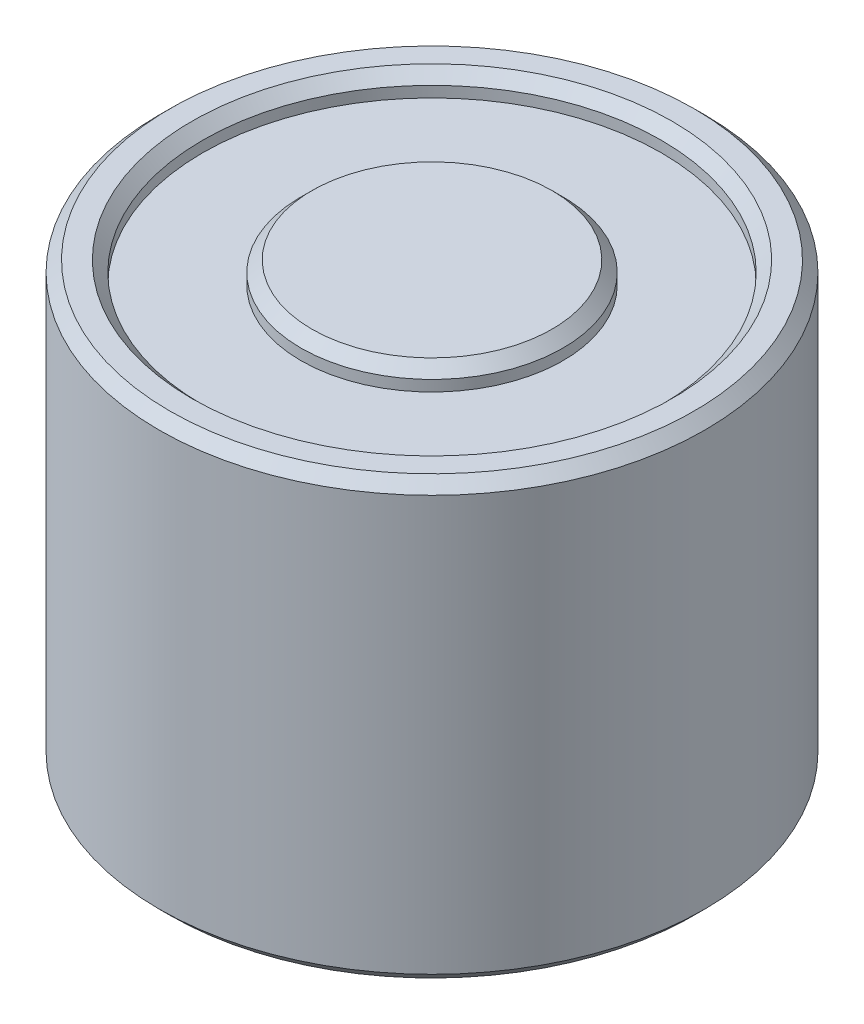
from build123d import *

# Parameters (mm, degrees)
SKETCH_1_R          = 12.5
EXTRUDE_1_DEPTH     = 20
SKETCH_2_R          = 10.5
SKETCH_2_R_2        = 6
CUT_EXTRUDE_1_DEPTH = 1
CHAMFER_1_SIZE      = 0.5
SKETCH_3_R          = 2
CUT_EXTRUDE_2_DEPTH = 12
CHAMFER_2_SIZE      = 1


with BuildPart() as part:
    # Эскиз1 → Бобышка-Вытянуть1 (new body)
    with BuildSketch(Plane(origin=(0, 0, 0), x_dir=(1, 0, 0), z_dir=(0, 1, 0))):
        Circle(SKETCH_1_R)
    extrude(amount=EXTRUDE_1_DEPTH)

    # Эскиз2 → Вырез-Вытянуть1 (cut)
    with BuildSketch(Plane(origin=(0, 20, 0), x_dir=(1, 0, 0), z_dir=(0, 1, 0))):
        Circle(SKETCH_2_R)
        Circle(SKETCH_2_R_2, mode=Mode.SUBTRACT)
    extrude(amount=-CUT_EXTRUDE_1_DEPTH, mode=Mode.SUBTRACT)

    # Фаска1
    chamfer_1_edges = [part.edges().sort_by_distance(p)[0] for p in [
        (-12.5, 0, 0),
        (-12.5, 20, 0),
        (-10.5, 20, 0),
        (-6, 20, 0),
    ]]
    chamfer(chamfer_1_edges, length=CHAMFER_1_SIZE)

    # Эскиз3 → Вырез-Вытянуть2 (cut)
    with BuildSketch(Plane.XZ):
        Circle(SKETCH_3_R)
    extrude(amount=-CUT_EXTRUDE_2_DEPTH, mode=Mode.SUBTRACT)

    # Фаска2
    chamfer_2_edges = [part.edges().sort_by_distance(p)[0] for p in [
        (-2, 0, 0),
    ]]
    chamfer(chamfer_2_edges, length=CHAMFER_2_SIZE)


solid = part.part
